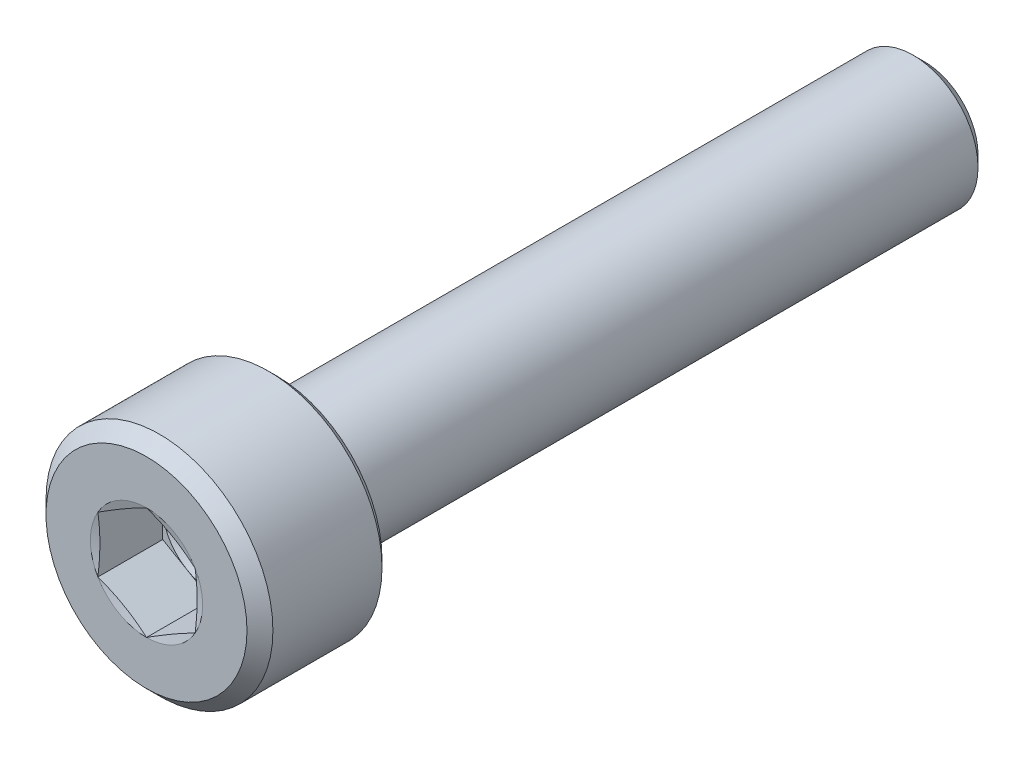
from build123d import *

# Parameters (mm, degrees)
CUT_EXTRUDE1_DEPTH = 2


with BuildPart() as part:
    # Sketch1 → Revolve1 (revolve)
    with BuildSketch(Plane(origin=(0, 0, 0), x_dir=(0, 0, -1), z_dir=(1, 0, 0))):
        with BuildLine():
            Line((0, 0), (0, 3.1))
            Line((0, 3.1), (0.4, 3.5))
            Line((0.4, 3.5), (3.765, 3.5))
            Line((3.765, 3.5), (4, 3.265))
            Line((4, 3.265), (4, 2.35))
            ThreePointArc((4, 2.35), (4.035614876, 2.236081032), (4.129775312, 2.162734164))
            Line((4.129775312, 2.162734164), (4.529775312, 2.012734164))
            ThreePointArc((4.529775312, 2.012734164), (4.564315039, 2.00320929), (4.6, 2))
            Line((4.6, 2), (23.65, 2))
            Line((23.65, 2), (24, 1.65))
            Line((24, 1.65), (24, 0))
            Line((24, 0), (0, 0))
        make_face()
    revolve(axis=Axis((0, 0, 0), (0, 0, -1)))

    # Sketch2 → Cut-Extrude1 (cut)
    with BuildSketch(Plane.XY):
        Polygon((0, 1.732050808), (-1.5, 0.866025404), (-1.5, -0.866025404), (0, -1.732050808), (1.5, -0.866025404), (1.5, 0.866025404), align=None)
    extrude(amount=-CUT_EXTRUDE1_DEPTH, mode=Mode.SUBTRACT)

    # Sketch3 → Cut-Revolve2 (revolve, cut)
    with BuildSketch(Plane(origin=(0, 0, 0), x_dir=(0, 0, -1), z_dir=(1, 0, 0))):
        Polygon((2, 0), (2, 1.5), (2.866025404, 0), align=None)
    revolve(axis=Axis((0, 0, -2), (0, 0, -1)), mode=Mode.SUBTRACT)

    # Sketch4 → Cut-Revolve3 (revolve, cut)
    with BuildSketch(Plane(origin=(0, 0, 0), x_dir=(0, 0, -1), z_dir=(1, 0, 0))):
        Polygon((0, 1.732050808), (0, 1.5), (0.062177826, 1.5), align=None)
    revolve(axis=Axis((0, 0, 0), (0, 0, -1)), mode=Mode.SUBTRACT)


solid = part.part
